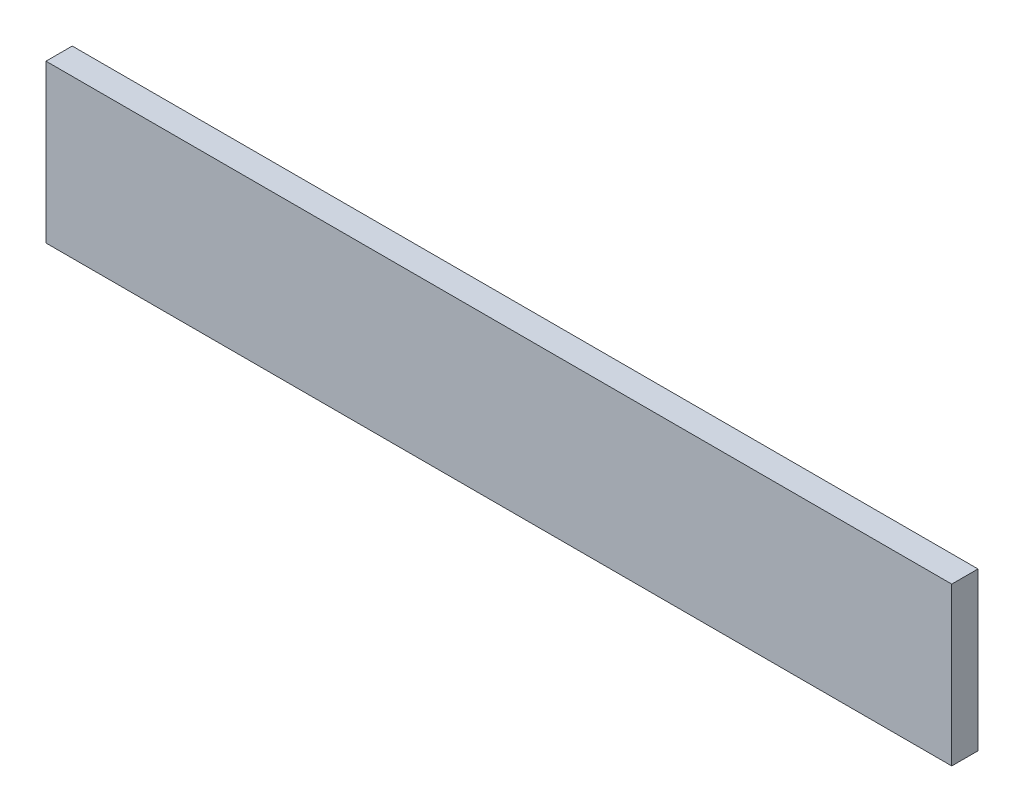
from build123d import *

# Parameters (mm, degrees)
SKETCH1_W           = 690
SKETCH1_H           = 120
BOSS_EXTRUDE1_DEPTH = 20


with BuildPart() as part:
    # Sketch1 → Boss-Extrude1 (new body)
    with BuildSketch(Plane.XY):
        with Locations((345, 60)):
            Rectangle(SKETCH1_W, SKETCH1_H)
    extrude(amount=BOSS_EXTRUDE1_DEPTH)


solid = part.part
